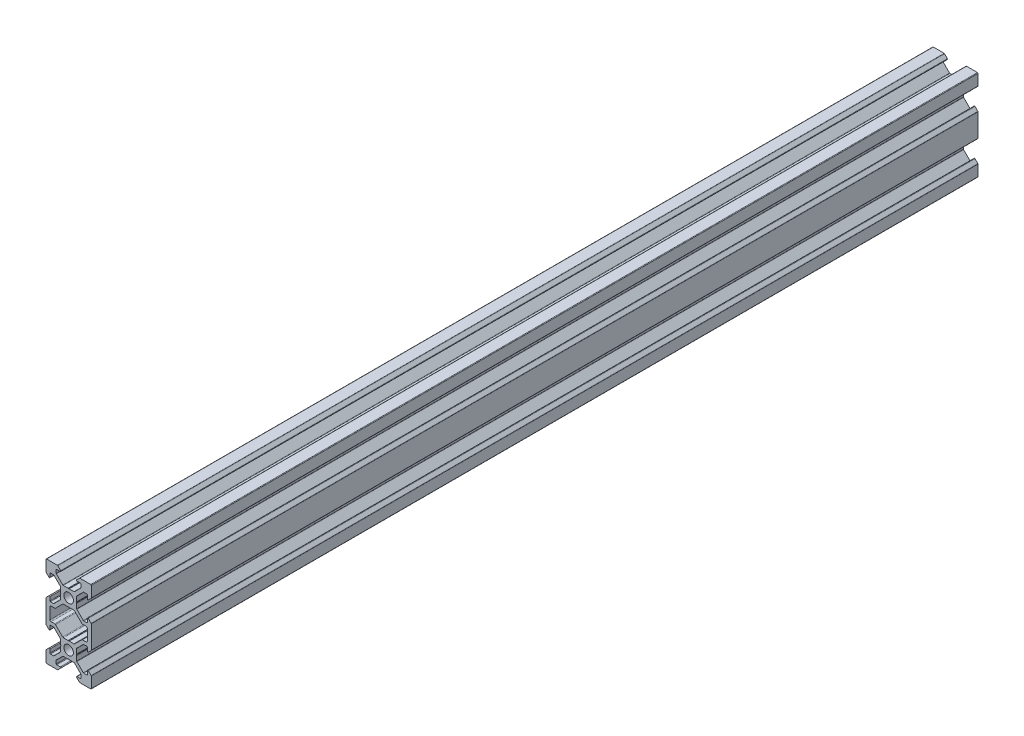
from build123d import *

# Parameters (mm, degrees)
SKETCH1_R           = 2.1
BOSS_EXTRUDE1_DEPTH = 391.83
FILLET1_R           = 0.25
FILLET2_R           = 0.5
CUT_EXTRUDE1_DEPTH  = 392.83


with BuildPart() as part:
    # Sketch1 → Boss-Extrude1 (new body)
    with BuildSketch(Plane.XY):
        Polygon((3.560660172, -2.5), (3.560660172, 2.5), (6.560660172, 5.5), (8.252142372, 5.5), (8.252142372, 3.1), (10, 4.847857628), (10, 10), (4.847857628, 10), (3.1, 8.252142372), (5.5, 8.252142372), (5.5, 6.560660172), (2.5, 3.560660172), (-2.5, 3.560660172), (-5.5, 6.560660172), (-5.5, 8.252142372), (-3.1, 8.252142372), (-4.847857628, 10), (-10, 10), (-10, 4.847857628), (-8.252142372, 3.1), (-8.252142372, 5.5), (-6.560660172, 5.5), (-3.560660172, 2.5), (-3.560660172, -2.5), (-6.560660172, -5.5), (-8.252142372, -5.5), (-8.252142372, -3.1), (-10, -4.847857628), (-10, -7), (-10, -13), (-10, -15.152142372), (-8.252142372, -16.9), (-8.252142372, -14.5), (-6.560660172, -14.5), (-3.560660172, -17.5), (-3.560660172, -22.5), (-6.560660172, -25.5), (-8.252142372, -25.5), (-8.252142372, -23.1), (-10, -24.847857628), (-10, -30), (-4.847857628, -30), (-3.1, -28.252142372), (-5.5, -28.252142372), (-5.5, -26.560660172), (-2.5, -23.560660172), (2.5, -23.560660172), (5.5, -26.560660172), (5.5, -28.252142372), (3.1, -28.252142372), (4.847857628, -30), (10, -30), (10, -24.847857628), (8.252142372, -23.1), (8.252142372, -25.5), (6.560660172, -25.5), (3.560660172, -22.5), (3.560660172, -17.5), (6.560660172, -14.5), (8.252142372, -14.5), (8.252142372, -16.9), (10, -15.152142372), (10, -13), (10, -7), (10, -4.847857628), (8.252142372, -3.1), (8.252142372, -5.5), (6.560660172, -5.5), align=None)
        Circle(SKETCH1_R, mode=Mode.SUBTRACT)
        with Locations((0, -20)):
            Circle(SKETCH1_R, mode=Mode.SUBTRACT)
        Polygon((2.5, -3.560660172), (-2.5, -3.560660172), (-5.5, -6.560660172), (-5.939339828, -7), (-8.252142372, -7), (-8.252142372, -13), (-5.939339828, -13), (-5.5, -13.439339828), (-2.5, -16.439339828), (2.5, -16.439339828), (5.5, -13.439339828), (5.939339828, -13), (8.252142372, -13), (8.252142372, -7), (5.939339828, -7), (5.5, -6.560660172), align=None, mode=Mode.SUBTRACT)
    extrude(amount=BOSS_EXTRUDE1_DEPTH)

    # Fillet1
    fillet1_edges = [part.edges().sort_by_distance(p)[0] for p in [
        (5.5, 6.560660172, 195.915),
        (5.5, 8.252142372, 195.915),
        (3.1, 8.252142372, 195.915),
        (4.847857628, 10, 195.915),
        (10, 10, 195.915),
        (10, 4.847857628, 195.915),
        (8.252142372, 3.1, 195.915),
        (8.252142372, 5.5, 195.915),
        (6.560660172, 5.5, 195.915),
        (3.560660172, 2.5, 195.915),
        (3.560660172, -2.5, 195.915),
        (6.560660172, -5.5, 195.915),
        (8.252142372, -5.5, 195.915),
        (8.252142372, -3.1, 195.915),
        (10, -4.847857628, 195.915),
        (10, -15.152142372, 195.915),
        (8.252142372, -16.9, 195.915),
        (8.252142372, -14.5, 195.915),
        (6.560660172, -14.5, 195.915),
        (3.560660172, -17.5, 195.915),
        (3.560660172, -22.5, 195.915),
        (6.560660172, -25.5, 195.915),
        (8.252142372, -25.5, 195.915),
        (8.252142372, -23.1, 195.915),
        (10, -24.847857628, 195.915),
        (10, -30, 195.915),
        (4.847857628, -30, 195.915),
        (3.1, -28.252142372, 195.915),
        (5.5, -28.252142372, 195.915),
        (5.5, -26.560660172, 195.915),
        (2.5, -23.560660172, 195.915),
        (-2.5, -23.560660172, 195.915),
        (-5.5, -26.560660172, 195.915),
        (-5.5, -28.252142372, 195.915),
        (-3.1, -28.252142372, 195.915),
        (-4.847857628, -30, 195.915),
        (-10, -30, 195.915),
        (-10, -24.847857628, 195.915),
        (-8.252142372, -23.1, 195.915),
        (-8.252142372, -25.5, 195.915),
        (-6.560660172, -25.5, 195.915),
        (-3.560660172, -22.5, 195.915),
        (-3.560660172, -17.5, 195.915),
        (-6.560660172, -14.5, 195.915),
        (-8.252142372, -14.5, 195.915),
        (-8.252142372, -16.9, 195.915),
        (-10, -15.152142372, 195.915),
        (-10, -4.847857628, 195.915),
        (-8.252142372, -3.1, 195.915),
        (-8.252142372, -5.5, 195.915),
        (-6.560660172, -5.5, 195.915),
        (-3.560660172, -2.5, 195.915),
        (-3.560660172, 2.5, 195.915),
        (-6.560660172, 5.5, 195.915),
        (-8.252142372, 5.5, 195.915),
        (-8.252142372, 3.1, 195.915),
        (-10, 4.847857628, 195.915),
        (-10, 10, 195.915),
        (-4.847857628, 10, 195.915),
        (-3.1, 8.252142372, 195.915),
        (-5.5, 8.252142372, 195.915),
        (-5.5, 6.560660172, 195.915),
        (-2.5, 3.560660172, 195.915),
        (2.5, 3.560660172, 195.915),
    ]]
    fillet(fillet1_edges, radius=FILLET1_R)

    # Fillet2
    fillet2_edges = [part.edges().sort_by_distance(p)[0] for p in [
        (-2.5, -3.560660172, 195.915),
        (-5.939339828, -7, 195.915),
        (-8.252142372, -7, 195.915),
        (-8.252142372, -13, 195.915),
        (-5.939339828, -13, 195.915),
        (-2.5, -16.439339828, 195.915),
        (2.5, -16.439339828, 195.915),
        (5.939339828, -13, 195.915),
        (8.252142372, -13, 195.915),
        (8.252142372, -7, 195.915),
        (5.939339828, -7, 195.915),
        (2.5, -3.560660172, 195.915),
    ]]
    fillet(fillet2_edges, radius=FILLET2_R)

    # Sketch2 → Cut-Extrude1 (cut, through all)
    with BuildSketch(Plane.XY.offset(391.83)):
        Polygon((0, 3.398953432), (-0.242280927, 3.560660172), (0.242280927, 3.560660172), align=None)
        Polygon((0, -3.398953432), (0.242280927, -3.560660172), (-0.242280927, -3.560660172), align=None)
        Polygon((3.560660172, 0.242280927), (3.560660172, -0.242280927), (3.398953432, 0), align=None)
        Polygon((-3.560660172, 0.242280927), (-3.560660172, -0.242280927), (-3.398953432, 0), align=None)
        Polygon((-3.398953432, -20), (-3.560660172, -20.242280927), (-3.560660172, -19.757719073), align=None)
        Polygon((3.398953432, -20), (3.560660172, -19.757719073), (3.560660172, -20.242280927), align=None)
        Polygon((-0.242280927, -16.439339828), (0.242280927, -16.439339828), (0, -16.601046568), align=None)
        Polygon((-0.242280927, -23.560660172), (0.242280927, -23.560660172), (0, -23.398953432), align=None)
    extrude(amount=-CUT_EXTRUDE1_DEPTH, mode=Mode.SUBTRACT)


solid = part.part
